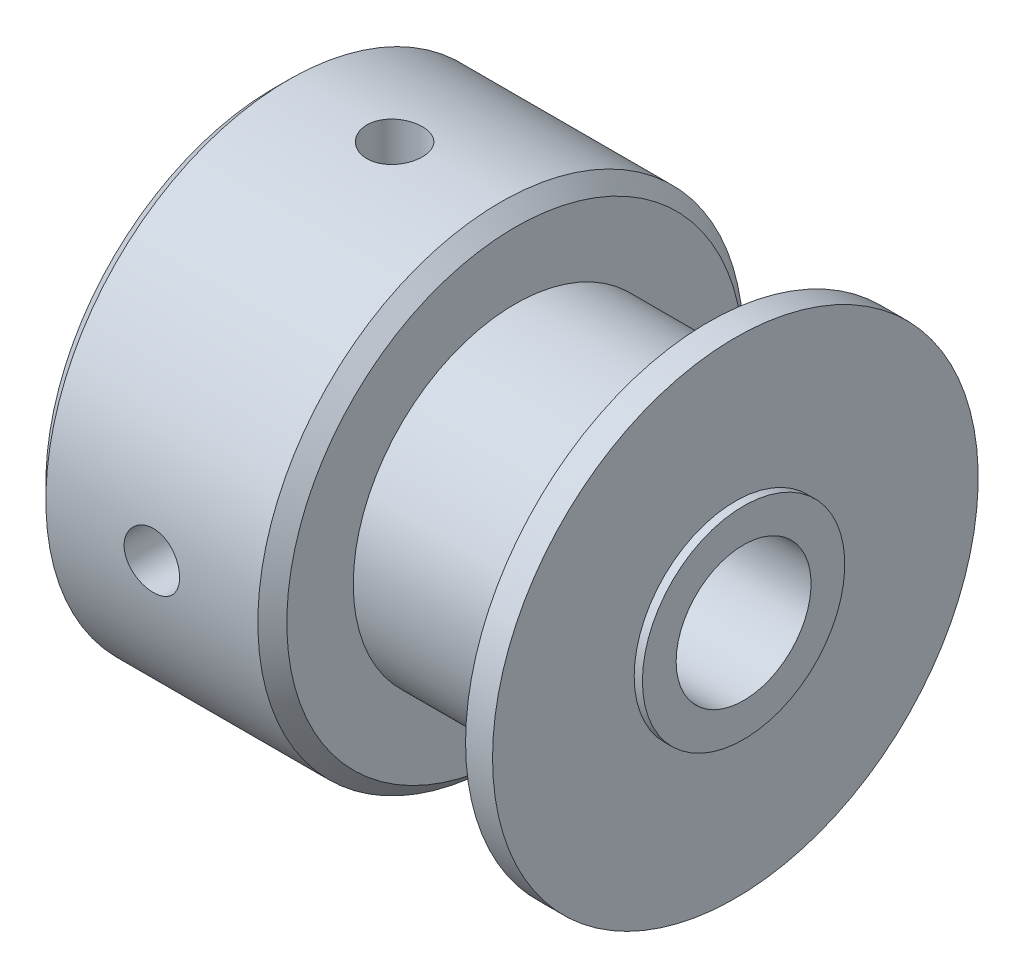
from build123d import *

# Parameters (mm, degrees)
SKETCH4_W         = 1
SKETCH4_H         = 5.25
SKETCH5_R         = 1.0287
SET_SCREWS_DEPTH  = 10
CIRPATTERN1_COUNT = 2
CIRPATTERN1_ANGLE = 90


with BuildPart() as part:
    # Sketch2 → Base Body (revolve)
    with BuildSketch(Plane.XY):
        Polygon((-8.7, 2.5), (8.7, 2.5), (8.7, 3.75), (7.395, 3.75), (7.395, 6), (0.2322, 6), (0.2322, 3.75), (-8.7, 3.75), align=None)
    revolve(axis=Axis((-7.1374, 0, 0), (1, 0, 0)))


with BuildPart() as body_2:
    # Sketch3 → Hub (revolve)
    with BuildSketch(Plane(origin=(0, 0, 0), x_dir=(1, 0, 0), z_dir=(0, 1, 0))):
        Polygon((0.2322, 3.75), (-8.7, 3.75), (-8.7, 8.46279), (-8.16279, 9), (-0.30501, 9), (0.2322, 8.46279), align=None)
    revolve(axis=Axis((0, 0, 0), (-1, 0, 0)))


with BuildPart() as body_3:
    # Sketch4 → Flange (revolve)
    with BuildSketch(Plane(origin=(0, 0, 0), x_dir=(1, 0, 0), z_dir=(0, 1, 0))):
        with Locations((7.895, 6.375)):
            Rectangle(SKETCH4_W, SKETCH4_H)
    revolve(axis=Axis((0, 0, 0), (1, 0, 0)))


with BuildPart() as set_screws_tool:
    # Sketch5 → Set Screws (new body)
    with BuildSketch(Plane(origin=(0, 0, 0), x_dir=(1, 0, 0), z_dir=(0, 1, 0))):
        with Locations((-4.2339, 0)):
            Circle(SKETCH5_R)
    set_screws = extrude(amount=SET_SCREWS_DEPTH)


with BuildPart() as part_1:
    add(part.part)

    # Set Screws: cut by set_screws_tool
    add(set_screws_tool.part, mode=Mode.SUBTRACT)


with BuildPart() as body_2_1:
    add(body_2.part)

    # Set Screws: cut by set_screws_tool
    add(set_screws_tool.part, mode=Mode.SUBTRACT)


with BuildPart() as cirpattern1_tool:
    # CirPattern1: Set Screws ×2 about axis
    cirpattern1_axis = Axis((-7.1374, 0, 0), (1, 0, 0))
    for i in range(1, CIRPATTERN1_COUNT):
        add(set_screws.rotate(cirpattern1_axis, i * CIRPATTERN1_ANGLE / (CIRPATTERN1_COUNT - 1)))


with BuildPart() as part_2:
    add(part_1.part)

    # CirPattern1: cut by cirpattern1_tool
    add(cirpattern1_tool.part, mode=Mode.SUBTRACT)


with BuildPart() as body_2_2:
    add(body_2_1.part)

    # CirPattern1: cut by cirpattern1_tool
    add(cirpattern1_tool.part, mode=Mode.SUBTRACT)


solid = Compound([body_3.part, part_2.part, body_2_2.part])
